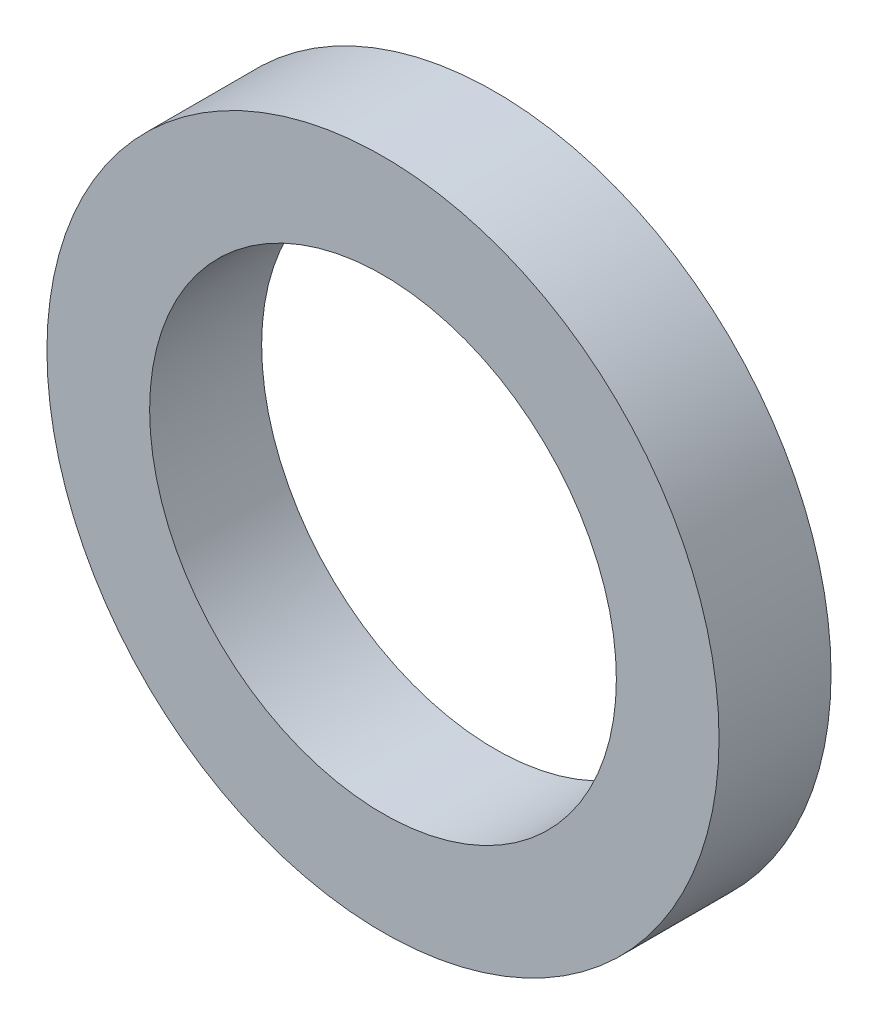
from build123d import *

# Parameters (mm, degrees)
SKETCH_1_R      = 9
SKETCH_1_R_2    = 6.25
EXTRUDE_1_DEPTH = 3


with BuildPart() as part:
    # 草图1 → 凸台-拉伸1 (new body)
    with BuildSketch(Plane.XY):
        Circle(SKETCH_1_R)
        Circle(SKETCH_1_R_2, mode=Mode.SUBTRACT)
    extrude(amount=EXTRUDE_1_DEPTH)


solid = part.part
